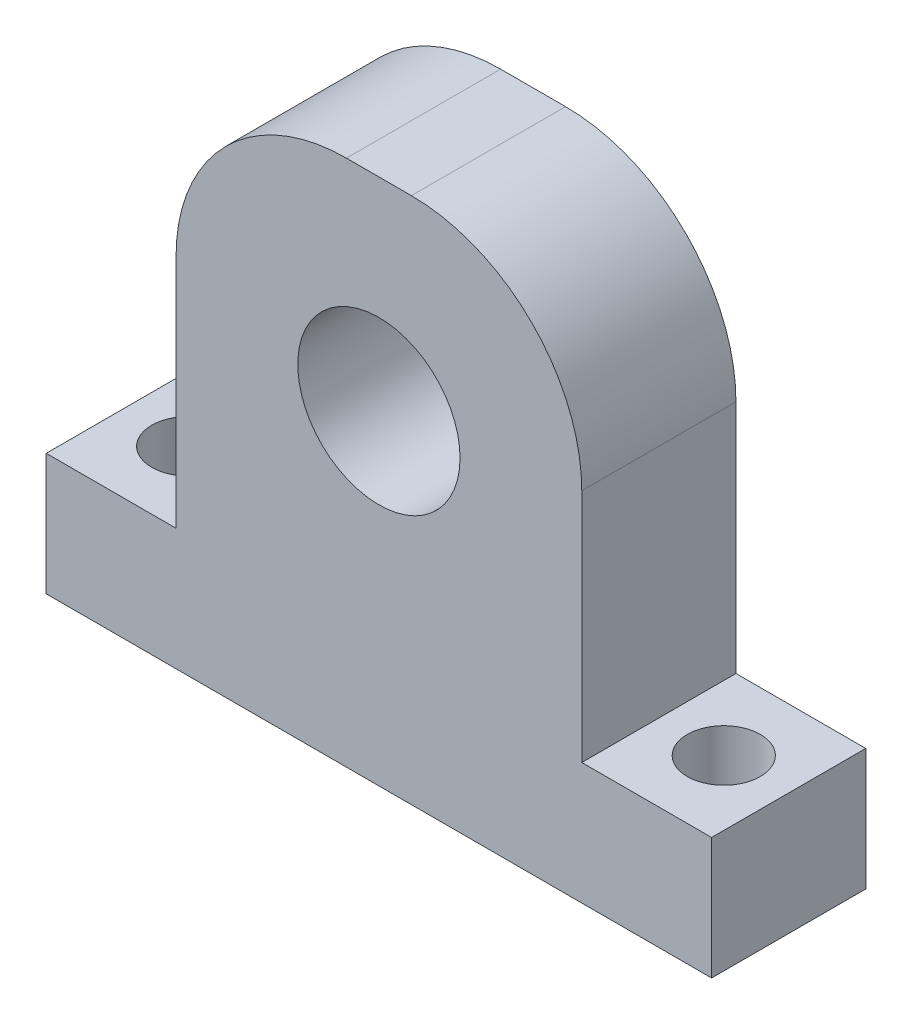
from build123d import *

# Parameters (mm, degrees)
SKETCH_1_W          = 50
SKETCH_1_H          = 50
SKETCH_1_R          = 10
SKETCH_1_W_2        = 82
SKETCH_1_H_2        = 15
EXTRUDE_1_DEPTH     = 19
FILLET_1_R          = 21
FILLET_3_R          = 21
SKETCH_2_R          = 4.5
CUT_EXTRUDE_1_DEPTH = 19


with BuildPart() as part:
    # 草图1 → 凸台-拉伸1 (new body)
    with BuildSketch(Plane.XY):
        with Locations((0, 32.5)):
            Rectangle(SKETCH_1_W, SKETCH_1_H)
        with Locations((0, 32.5)):
            Circle(SKETCH_1_R, mode=Mode.SUBTRACT)
        Rectangle(SKETCH_1_W_2, SKETCH_1_H_2)
    extrude(amount=EXTRUDE_1_DEPTH)

    # 圆角1
    fillet_1_edges = [part.edges().sort_by_distance(p)[0] for p in [
        (-25, 57.5, 9.5),
    ]]
    fillet(fillet_1_edges, radius=FILLET_1_R)

    # 圆角3
    fillet_3_edges = [part.edges().sort_by_distance(p)[0] for p in [
        (25, 57.5, 9.5),
    ]]
    fillet(fillet_3_edges, radius=FILLET_3_R)

    # 草图2 → 切除-拉伸1 (cut)
    with BuildSketch(Plane.XZ.offset(7.5)):
        with Locations((-33, 9.5)):
            Circle(SKETCH_2_R)
        with Locations((33, 9.5)):
            Circle(SKETCH_2_R)
    extrude(amount=-CUT_EXTRUDE_1_DEPTH, mode=Mode.SUBTRACT)


solid = part.part
